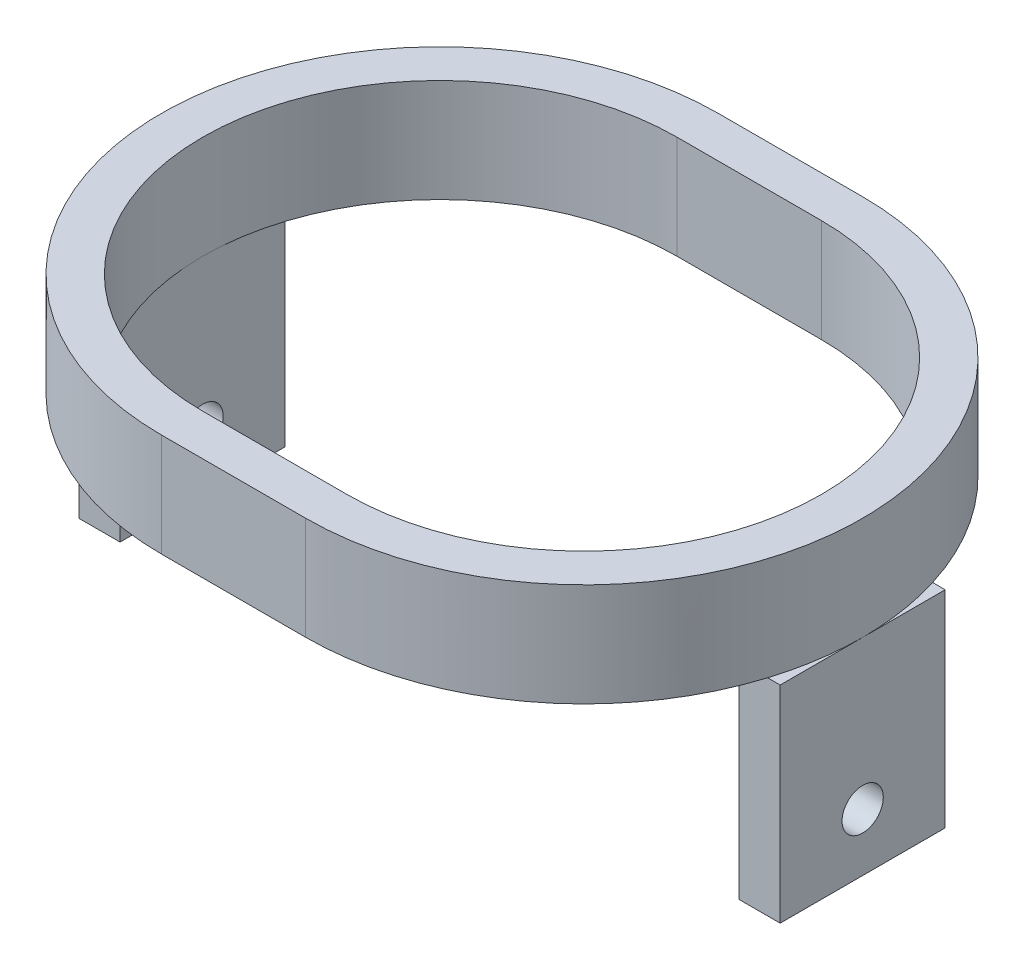
from build123d import *

# Parameters (mm, degrees)
EXTRUDE_1_DEPTH     = 10
SKETCH_3_W          = 4
SKETCH_3_H          = 16
EXTRUDE_2_DEPTH     = 20
SKETCH_5_R          = 2
CUT_EXTRUDE_2_DEPTH = 69


with BuildPart() as part:
    # 草图2 → 凸台-拉伸1 (new body)
    with BuildSketch(Plane(origin=(0, 0, 0), x_dir=(1, 0, 0), z_dir=(0, 1, 0))):
        with BuildLine():
            Line((-7, 27), (7, 27))
            ThreePointArc((7, 27), (34, 0), (7, -27))
            Line((7, -27), (-7, -27))
            ThreePointArc((-7, -27), (-34, 0), (-7, 27))
        make_face()
        with BuildLine():
            Line((-7, 23), (7, 23))
            ThreePointArc((7, 23), (30, 0), (7, -23))
            Line((7, -23), (-7, -23))
            ThreePointArc((-7, -23), (-30, 0), (-7, 23))
        make_face(mode=Mode.SUBTRACT)
    extrude(amount=EXTRUDE_1_DEPTH)

    # 草图3 → 凸台-拉伸2 (add)
    with BuildSketch(Plane.XZ):
        with Locations((-32, 0)):
            Rectangle(SKETCH_3_W, SKETCH_3_H)
        with Locations((32, 0)):
            Rectangle(SKETCH_3_W, SKETCH_3_H)
    extrude(amount=EXTRUDE_2_DEPTH)

    # 草图5 → 切除-拉伸2 (cut, through all)
    with BuildSketch(Plane(origin=(34, 0, 0), x_dir=(0, 0, -1), z_dir=(1, 0, 0))):
        with Locations((0, -14.426533044)):
            Circle(SKETCH_5_R)
    extrude(amount=-CUT_EXTRUDE_2_DEPTH, mode=Mode.SUBTRACT)


solid = part.part
